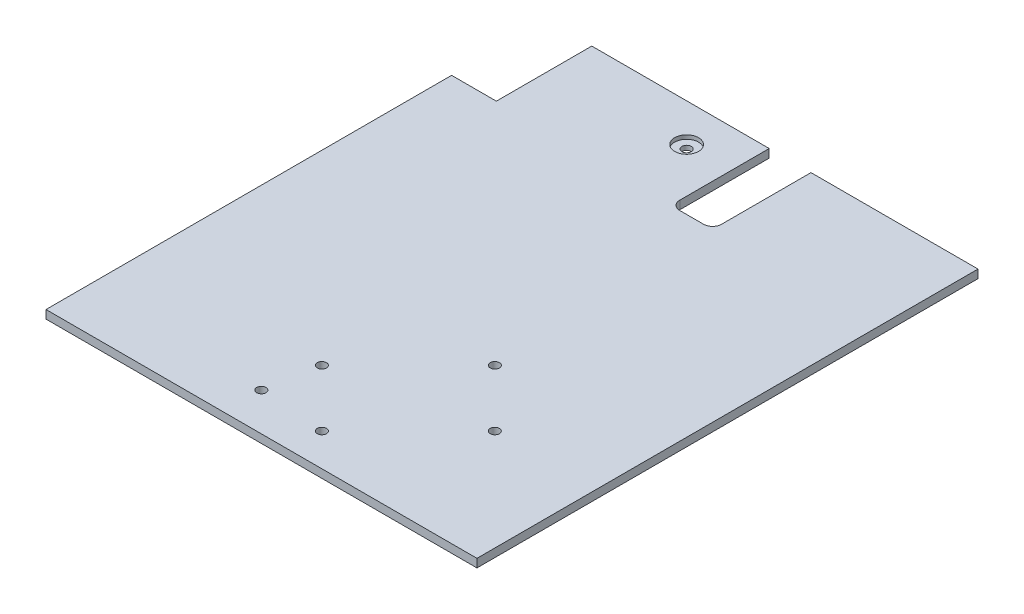
from build123d import *

# Parameters (mm, degrees)
SKETCH1_R           = 1.55
BOSS_EXTRUDE1_DEPTH = 2.8
CUT_EXTRUDE1_REACH  = 4.8
SKETCH2_R           = 1.55
SKETCH3_R           = 4
CUT_EXTRUDE2_DEPTH  = 1.3
CUT_EXTRUDE3_REACH  = 4.8


with BuildPart() as part:
    # Sketch1 → Boss-Extrude1 (new body)
    with BuildSketch(Plane(origin=(0, 0, 0), x_dir=(1, 0, 0), z_dir=(0, 1, 0))):
        Polygon((-72.25, 52), (-72.25, -84), (72.25, -84), (72.25, 84), (-57.25, 84), (-57.25, 52), align=None)
        with Locations((-9.79163056, -53.949747468)):
            Circle(SKETCH1_R, mode=Mode.SUBTRACT)
        with Locations((9.300252532, -73.04163056)):
            Circle(SKETCH1_R, mode=Mode.SUBTRACT)
        with Locations((38.29163056, -44.050252532)):
            Circle(SKETCH1_R, mode=Mode.SUBTRACT)
        with Locations((19.199747468, -24.95836944)):
            Circle(SKETCH1_R, mode=Mode.SUBTRACT)
    extrude(amount=BOSS_EXTRUDE1_DEPTH)

    # Sketch2 → Cut-Extrude1 (cut, up to next)
    with BuildSketch(Plane(origin=(0, 2.8, 0), x_dir=(1, 0, 0), z_dir=(0, 1, 0)), mode=Mode.PRIVATE) as cut_extrude1_sk1:
        with Locations((-12.75, 71.3)):
            Circle(SKETCH2_R)
    cut_extrude1_tool1 = extrude(cut_extrude1_sk1.sketch, amount=-CUT_EXTRUDE1_REACH, mode=Mode.PRIVATE) & part.part
    add(cut_extrude1_tool1.solids().sort_by_distance((-12.75, 2.8, -71.3))[0], mode=Mode.SUBTRACT)
    # Sketch2 → Cut-Extrude1 (cut, up to next)
    with BuildSketch(Plane(origin=(0, 2.8, 0), x_dir=(1, 0, 0), z_dir=(0, 1, 0)), mode=Mode.PRIVATE) as cut_extrude1_sk2:
        with Locations((-12.75, -71.3)):
            Circle(SKETCH2_R)
    cut_extrude1_tool2 = extrude(cut_extrude1_sk2.sketch, amount=-CUT_EXTRUDE1_REACH, mode=Mode.PRIVATE) & part.part
    add(cut_extrude1_tool2.solids().sort_by_distance((-12.75, 2.8, 71.3))[0], mode=Mode.SUBTRACT)

    # Sketch3 → Cut-Extrude2 (cut)
    with BuildSketch(Plane(origin=(0, 2.8, 0), x_dir=(1, 0, 0), z_dir=(0, 1, 0))):
        with Locations((-12.75, 71.3)):
            Circle(SKETCH3_R)
    extrude(amount=-CUT_EXTRUDE2_DEPTH, mode=Mode.SUBTRACT)

    # Sketch4 → Cut-Extrude3 (cut, up to next)
    with BuildSketch(Plane(origin=(0, 2.8, 0), x_dir=(1, 0, 0), z_dir=(0, 1, 0)), mode=Mode.PRIVATE) as cut_extrude3_sk1:
        with BuildLine():
            Line((16.25, 84), (2.25, 84))
            Line((2.25, 84), (2.25, 54))
            ThreePointArc((2.25, 54), (3.128679656, 51.878679656), (5.25, 51))
            Line((5.25, 51), (13.25, 51))
            ThreePointArc((13.25, 51), (15.371320344, 51.878679656), (16.25, 54))
            Line((16.25, 54), (16.25, 84))
        make_face()
    cut_extrude3_tool1 = extrude(cut_extrude3_sk1.sketch, amount=-CUT_EXTRUDE3_REACH, mode=Mode.PRIVATE) & part.part
    add(cut_extrude3_tool1.solids().sort_by_distance((9.25, 2.8, -67.633471))[0], mode=Mode.SUBTRACT)


solid = part.part
